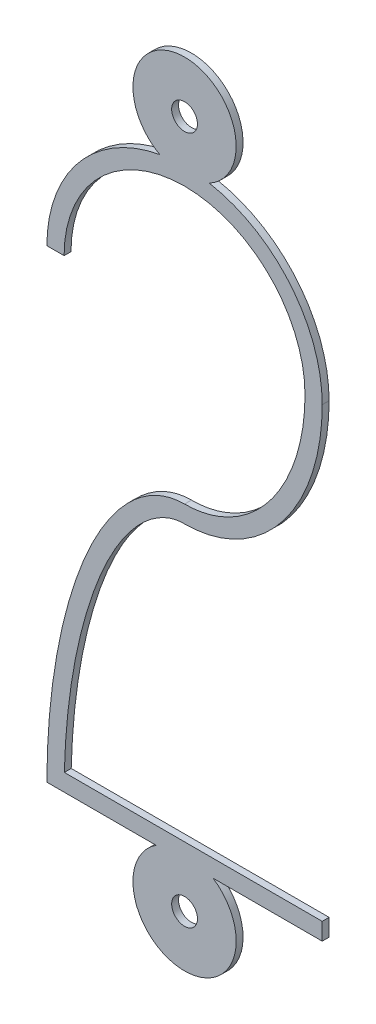
from build123d import *

# Parameters (mm, degrees)
SKETCH1_R           = 0.375
BOSS_EXTRUDE1_DEPTH = 0.1


with BuildPart() as part:
    # Sketch1 → Boss-Extrude1 (new, symmetric)
    with BuildSketch(Plane.XY):
        with BuildLine():
            Line((-4, -8.75), (-0.829156198, -8.75))
            ThreePointArc((-0.829156198, -8.75), (0, -11.5), (0.829156198, -8.75))
            Line((0.829156198, -8.75), (4, -8.75))
            Line((4, -8.75), (4, -8.25))
            Line((4, -8.25), (-3.493665639, -8.25))
            add(Edge.make_bspline(
                [(0, -0.25), (-0.19681399, -0.25), (-0.563170918, -0.33008016), (-1.190329619, -0.745580795), (-1.814545501, -1.492748086), (-2.578198545, -2.89649561), (-3.152684383, -4.822836812), (-3.427979519, -6.864701359), (-3.483242067, -7.843950964), (-3.493665639, -8.25)],
                knots=[3.141592654, 3.141592654, 3.141592654, 3.141592654, 3.337942194, 3.534291735, 3.730641276, 3.926990817, 4.319689899, 4.51603944, 4.655206248, 4.655206248, 4.655206248, 4.655206248], degree=3))
            add(Edge.make_bspline(
                [(0, -0.25), (4, -0.25), (4, 4.75)],
                knots=[3.141592654, 3.141592654, 3.141592654, 4.71238898, 4.71238898, 4.71238898], degree=2, weights=[1, 0.707106781, 1]))
            ThreePointArc((4, 4.75), (3.072711837, 7.310945522), (0.720779018, 8.68452381))
            ThreePointArc((0.720779018, 8.68452381), (0, 11.5), (-0.720779018, 8.68452381))
            ThreePointArc((-0.720779018, 8.68452381), (-3.072711837, 7.310945522), (-4, 4.75))
            Line((-4, 4.75), (-3.5, 4.75))
            ThreePointArc((-3.5, 4.75), (0, 8.25), (3.5, 4.75))
            add(Edge.make_bspline(
                [(0, 0.25), (3.5, 0.25), (3.5, 4.75)],
                knots=[3.141592654, 3.141592654, 3.141592654, 4.71238898, 4.71238898, 4.71238898], degree=2, weights=[1, 0.707106781, 1]))
            add(Edge.make_bspline(
                [(0, 0.25), (-4, 0.25), (-4, -8.75)],
                knots=[0, 0, 0, 1.570796327, 1.570796327, 1.570796327], degree=2, weights=[1, 0.707106781, 1]))
        make_face()
        with Locations((0, 10)):
            Circle(SKETCH1_R, mode=Mode.SUBTRACT)
        with Locations((0, -10)):
            Circle(SKETCH1_R, mode=Mode.SUBTRACT)
    extrude(amount=BOSS_EXTRUDE1_DEPTH, both=True)


solid = part.part
